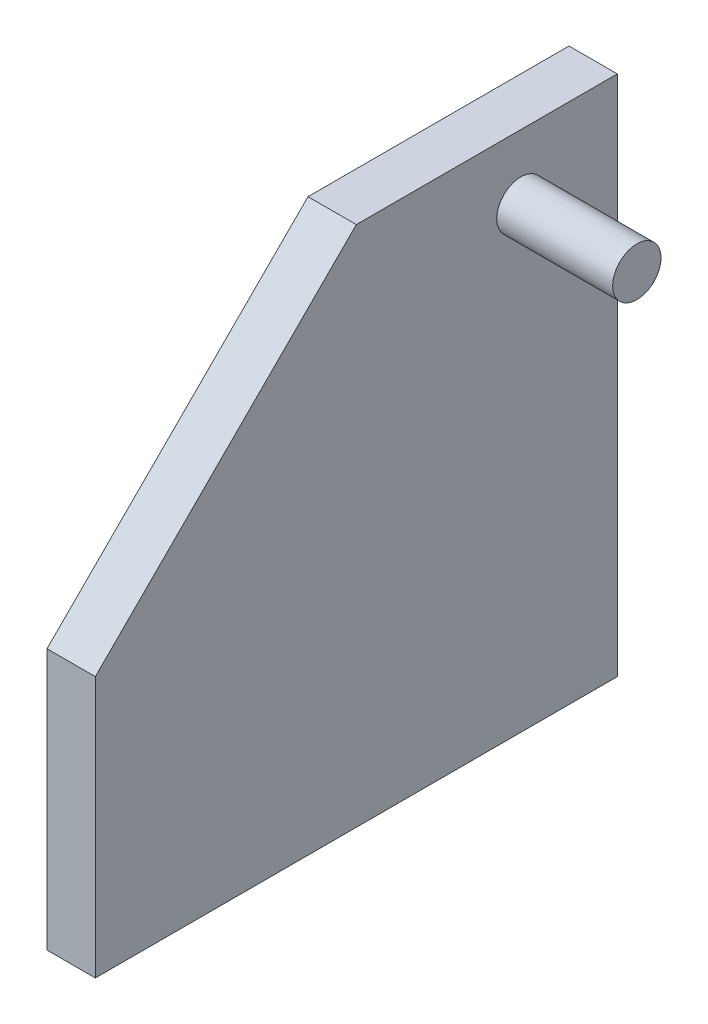
from build123d import *

# Parameters (mm, degrees)
SKETCH1_W           = 27
SKETCH1_H           = 27
BOSS_EXTRUDE1_DEPTH = 2.5
SKETCH2_R           = 1.25
BOSS_EXTRUDE2_DEPTH = 6
SKETCH3_W           = 10
SKETCH3_H           = 6
BOSS_EXTRUDE3_DEPTH = 7
CUT_EXTRUDE1_DEPTH  = 10.5


with BuildPart() as part:
    # Sketch1 → Boss-Extrude1 (new body)
    with BuildSketch(Plane(origin=(0, 0, 0), x_dir=(0, 0, -1), z_dir=(1, 0, 0))):
        with Locations((-28.770960436, -5.47612775)):
            Rectangle(SKETCH1_W, SKETCH1_H)
    extrude(amount=BOSS_EXTRUDE1_DEPTH)

    # Sketch2 → Boss-Extrude2 (add)
    with BuildSketch(Plane(origin=(2.5, 0, 0), x_dir=(0, 0, -1), z_dir=(1, 0, 0))):
        with Locations((-20.260960436, 4.65387225)):
            Circle(SKETCH2_R)
    extrude(amount=BOSS_EXTRUDE2_DEPTH)

    # Sketch3 → Boss-Extrude3 (add)
    with BuildSketch(Plane.ZY):
        with Locations((27.270960436, -15.97612775)):
            Rectangle(SKETCH3_W, SKETCH3_H)
    extrude(amount=BOSS_EXTRUDE3_DEPTH)

    # Sketch4 → Cut-Extrude1 (cut, through all)
    with BuildSketch(Plane(origin=(2.5, 0, 0), x_dir=(0, 0, -1), z_dir=(1, 0, 0))):
        Polygon((-42.270960436, -5.47612775), (-28.770960436, 8.02387225), (-42.270960436, 8.02387225), align=None)
    extrude(amount=-CUT_EXTRUDE1_DEPTH, mode=Mode.SUBTRACT)


solid = part.part
